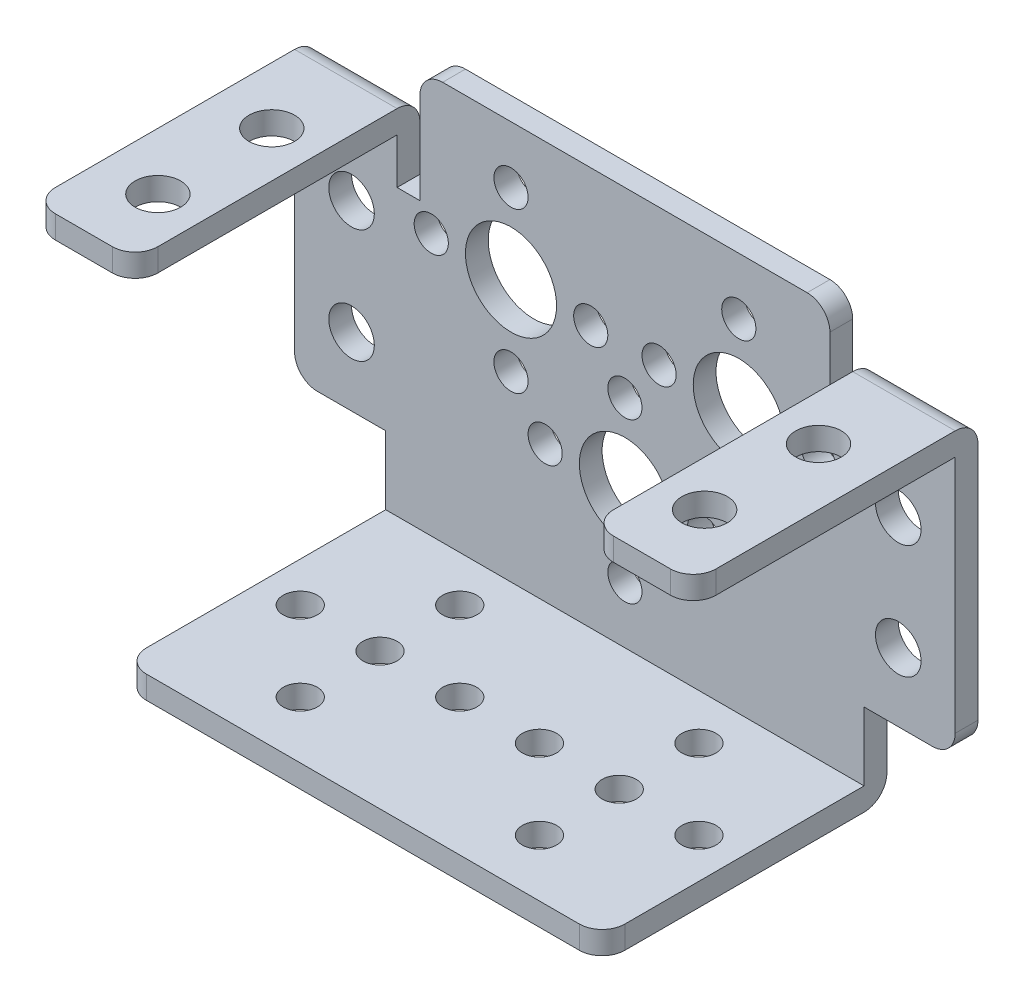
from build123d import *

# Parameters (mm, degrees)
BOSS_EXTRUDE1_DEPTH = 2
SKETCH1_3_W         = 42
SKETCH1_3_H         = 2
SKETCH1_3_W_2       = 9
BOSS_EXTRUDE2_DEPTH = 23
FILLET1_R           = 2
SKETCH2_R           = 1.5
CUT_EXTRUDE1_DEPTH  = 25
SKETCH3_R           = 2
SKETCH3_R_2         = 4
SKETCH3_R_3         = 1.5
CUT_EXTRUDE2_DEPTH  = 25
SKETCH4_R           = 2
CUT_EXTRUDE3_DEPTH  = 25


with BuildPart() as part:
    # Sketch1 → Boss-Extrude1 (new body)
    with BuildSketch(Plane.XY):
        with BuildLine():
            Line((-21, -18.5), (21, -18.5))
            Line((21, -18.5), (21, -10.5))
            Line((21, -10.5), (27, -10.5))
            ThreePointArc((27, -10.5), (28.414213562, -9.914213562), (29, -8.5))
            Line((29, -8.5), (29, 14.5))
            Line((29, 14.5), (20, 14.5))
            Line((20, 14.5), (20, 8.5))
            Line((20, 8.5), (18, 8.5))
            Line((18, 8.5), (18, 16.5))
            ThreePointArc((18, 16.5), (17.414213562, 17.914213562), (16, 18.5))
            Line((16, 18.5), (-16, 18.5))
            ThreePointArc((-16, 18.5), (-17.414213562, 17.914213562), (-18, 16.5))
            Line((-18, 16.5), (-18, 8.5))
            Line((-18, 8.5), (-20, 8.5))
            Line((-20, 8.5), (-20, 14.5))
            Line((-20, 14.5), (-29, 14.5))
            Line((-29, 14.5), (-29, -8.5))
            ThreePointArc((-29, -8.5), (-28.414213562, -9.914213562), (-27, -10.5))
            Line((-27, -10.5), (-21, -10.5))
            Line((-21, -10.5), (-21, -18.5))
        make_face()
    extrude(amount=-BOSS_EXTRUDE1_DEPTH)

    # Sketch1_3 → Boss-Extrude2 (add)
    with BuildSketch(Plane.XY):
        with Locations((0, -17.5)):
            Rectangle(SKETCH1_3_W, SKETCH1_3_H)
        with Locations((-24.5, 13.5)):
            Rectangle(SKETCH1_3_W_2, SKETCH1_3_H)
        with Locations((24.5, 13.5)):
            Rectangle(SKETCH1_3_W_2, SKETCH1_3_H)
    extrude(amount=BOSS_EXTRUDE2_DEPTH)

    # Fillet1
    fillet1_edges = [part.edges().sort_by_distance(p)[0] for p in [
        (0, -18.5, -2),
        (24.5, 14.5, -2),
        (-24.5, 14.5, -2),
        (-29, 13.5, 23),
        (-20, 13.5, 23),
        (20, 13.5, 23),
        (29, 13.5, 23),
        (-21, -17.5, 23),
        (21, -17.5, 23),
    ]]
    fillet(fillet1_edges, radius=FILLET1_R)

    # Sketch2 → Cut-Extrude1 (cut)
    with BuildSketch(Plane(origin=(0, -16.5, 0), x_dir=(1, 0, 0), z_dir=(0, 1, 0))):
        with Locations((17.5, -11)):
            Circle(SKETCH2_R)
        with Locations((10.5, -11)):
            Circle(SKETCH2_R)
        with Locations((10.5, -18)):
            Circle(SKETCH2_R)
        with Locations((3.5, -11)):
            Circle(SKETCH2_R)
        with Locations((10.5, -4)):
            Circle(SKETCH2_R)
        with Locations((-17.5, -11)):
            Circle(SKETCH2_R)
        with Locations((-10.5, -18)):
            Circle(SKETCH2_R)
        with Locations((-10.5, -11)):
            Circle(SKETCH2_R)
        with Locations((-3.5, -11)):
            Circle(SKETCH2_R)
        with Locations((-10.5, -4)):
            Circle(SKETCH2_R)
    extrude(amount=-CUT_EXTRUDE1_DEPTH, mode=Mode.SUBTRACT)

    # Sketch3 → Cut-Extrude2 (cut)
    with BuildSketch(Plane.XY):
        with Locations((-24, -4.5)):
            Circle(SKETCH3_R)
        with Locations((-24, 5.5)):
            Circle(SKETCH3_R)
        with Locations((-10, 6.5)):
            Circle(SKETCH3_R_2)
        with Locations((-3, 6.5)):
            Circle(SKETCH3_R_3)
        with Locations((-10, -0.5)):
            Circle(SKETCH3_R_3)
        with Locations((-17, 6.5)):
            Circle(SKETCH3_R_3)
        with Locations((-10, 13.5)):
            Circle(SKETCH3_R_3)
        with Locations((10, -0.5)):
            Circle(SKETCH3_R_3)
        with Locations((3, 6.5)):
            Circle(SKETCH3_R_3)
        with Locations((10, 13.5)):
            Circle(SKETCH3_R_3)
        with Locations((10, 6.5)):
            Circle(SKETCH3_R_2)
        with Locations((17, 6.5)):
            Circle(SKETCH3_R_3)
        with Locations((24, -4.5)):
            Circle(SKETCH3_R)
        with Locations((24, 5.5)):
            Circle(SKETCH3_R)
        with Locations((0, -4.5)):
            Circle(SKETCH3_R_2)
        with Locations((0, -11.5)):
            Circle(SKETCH3_R_3)
        with Locations((-7, -4.5)):
            Circle(SKETCH3_R_3)
        with Locations((0, 2.5)):
            Circle(SKETCH3_R_3)
        with Locations((7, -4.5)):
            Circle(SKETCH3_R_3)
    extrude(amount=-CUT_EXTRUDE2_DEPTH, mode=Mode.SUBTRACT)

    # Sketch4 → Cut-Extrude3 (cut)
    with BuildSketch(Plane(origin=(0, 14.5, 0), x_dir=(1, 0, 0), z_dir=(0, 1, 0))):
        with Locations((-24, -7)):
            Circle(SKETCH4_R)
        with Locations((-24, -17)):
            Circle(SKETCH4_R)
        with Locations((24, -17)):
            Circle(SKETCH4_R)
        with Locations((24, -7)):
            Circle(SKETCH4_R)
    extrude(amount=-CUT_EXTRUDE3_DEPTH, mode=Mode.SUBTRACT)


solid = part.part
